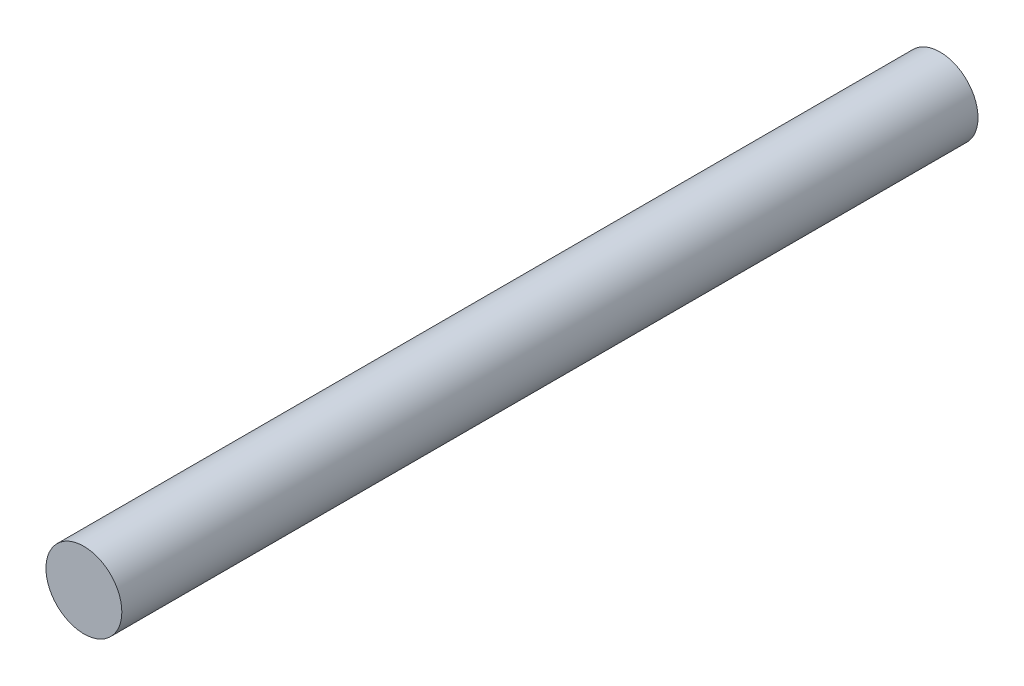
from build123d import *

# Parameters (mm, degrees)
SKETCH1_R           = 3.3782
BOSS_EXTRUDE1_DEPTH = 38.1


with BuildPart() as part:
    # Sketch1 → Boss-Extrude1 (new body, symmetric)
    with BuildSketch(Plane.XY):
        Circle(SKETCH1_R)
    extrude(amount=BOSS_EXTRUDE1_DEPTH, both=True)


solid = part.part
